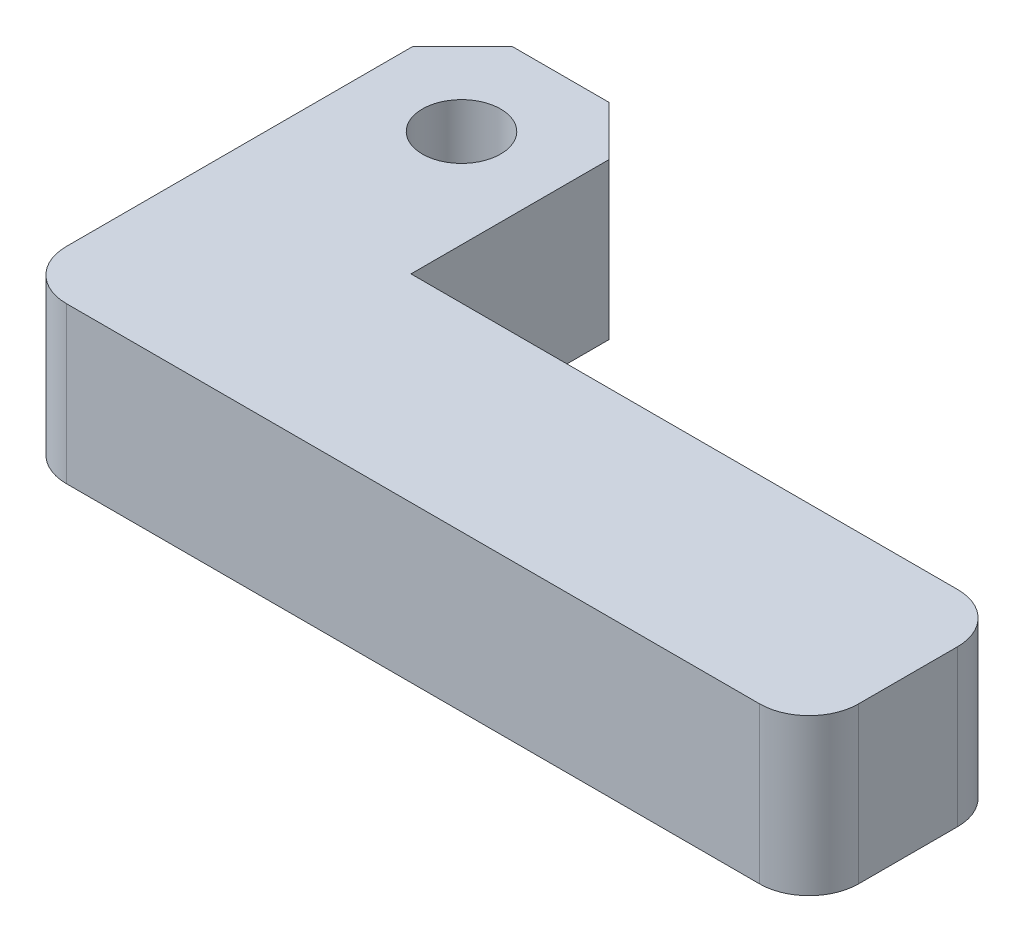
from build123d import *

# Parameters (mm, degrees)
SKETCH1_R           = 2.50825
BOSS_EXTRUDE1_DEPTH = 10
FILLET1_R           = 3.175
CHAMFER1_SIZE       = 3.175


with BuildPart() as part:
    # Sketch1 → Boss-Extrude1 (new body)
    with BuildSketch(Plane(origin=(0, 0, 0), x_dir=(1, 0, 0), z_dir=(0, 1, 0))):
        with BuildLine():
            Line((0, 28.575), (0, 0))
            Line((0, 0), (47.625, 0))
            ThreePointArc((47.625, 0), (49.87006403, 0.92993597), (50.8, 3.175))
            Line((50.8, 3.175), (50.8, 9.525))
            ThreePointArc((50.8, 9.525), (49.87006403, 11.77006403), (47.625, 12.7))
            Line((47.625, 12.7), (12.573, 12.7))
            Line((12.573, 12.7), (12.573, 28.575))
            Line((12.573, 28.575), (0, 28.575))
        make_face()
        with Locations((6.2865, 22.225)):
            Circle(SKETCH1_R, mode=Mode.SUBTRACT)
    extrude(amount=BOSS_EXTRUDE1_DEPTH)

    # Fillet1
    fillet1_edges = [part.edges().sort_by_distance(p)[0] for p in [
        (0, 5, 0),
    ]]
    fillet(fillet1_edges, radius=FILLET1_R)

    # Chamfer1
    chamfer1_edges = [part.edges().sort_by_distance(p)[0] for p in [
        (12.573, 5, -28.575),
        (0, 5, -28.575),
    ]]
    chamfer(chamfer1_edges, length=CHAMFER1_SIZE)


solid = part.part
